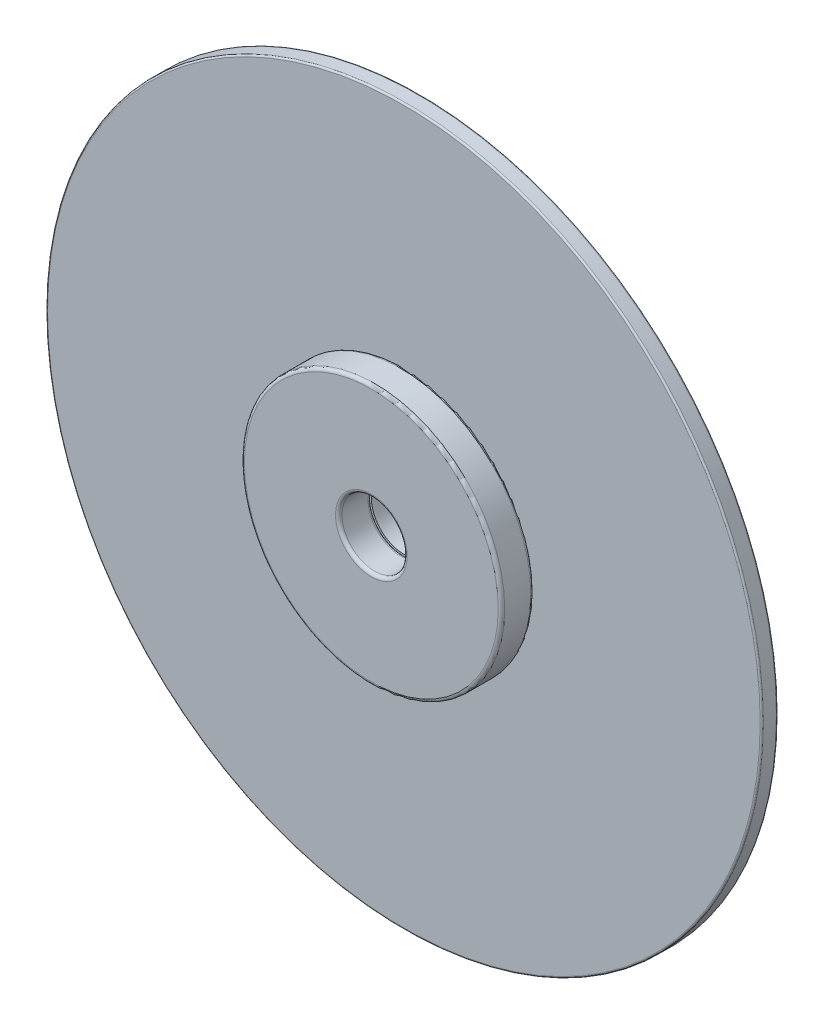
from build123d import *

# Parameters (mm, degrees)
SKETCH2_R           = 11
SKETCH2_R_2         = 1
BOSS_EXTRUDE1_DEPTH = 0.5
SKETCH3_R           = 4
SKETCH3_R_2         = 1
BOSS_EXTRUDE2_DEPTH = 1
SKETCH4_R           = 4
SKETCH4_R_2         = 1
BOSS_EXTRUDE3_DEPTH = 1
FILLET1_R           = 0.1
FILLET2_R           = 0.1
FILLET3_R           = 0.05


with BuildPart() as part:
    # Sketch2 → Boss-Extrude1 (new body)
    with BuildSketch(Plane.XY):
        Circle(SKETCH2_R)
        Circle(SKETCH2_R_2, mode=Mode.SUBTRACT)
    extrude(amount=BOSS_EXTRUDE1_DEPTH)

    # Fillet3
    fillet3_edges = [part.edges().sort_by_distance(p)[0] for p in [
        (-11, 0, 0),
        (-11, 0, 0.5),
    ]]
    fillet(fillet3_edges, radius=FILLET3_R)


with BuildPart() as body_2:
    # Sketch3 → Boss-Extrude2 (new body)
    with BuildSketch(Plane.XY.offset(0.5)):
        Circle(SKETCH3_R)
        Circle(SKETCH3_R_2, mode=Mode.SUBTRACT)
    extrude(amount=BOSS_EXTRUDE2_DEPTH)

    # Fillet2
    fillet2_edges = [body_2.edges().sort_by_distance(p)[0] for p in [
        (-4, 0, 0.5),
        (-4, 0, 1.5),
        (-1, 0, 0.5),
        (-1, 0, 1.5),
    ]]
    fillet(fillet2_edges, radius=FILLET2_R)


with BuildPart() as body_3:
    # Sketch4 → Boss-Extrude3 (new body)
    with BuildSketch(Plane(origin=(0, 0, 0), x_dir=(-1, 0, 0), z_dir=(0, 0, -1))):
        Circle(SKETCH4_R)
        Circle(SKETCH4_R_2, mode=Mode.SUBTRACT)
    extrude(amount=BOSS_EXTRUDE3_DEPTH)

    # Fillet1
    fillet1_edges = [body_3.edges().sort_by_distance(p)[0] for p in [
        (4, 0, 0),
        (4, 0, -1),
        (1, 0, -1),
    ]]
    fillet(fillet1_edges, radius=FILLET1_R)


solid = Compound([part.part, body_2.part, body_3.part])
